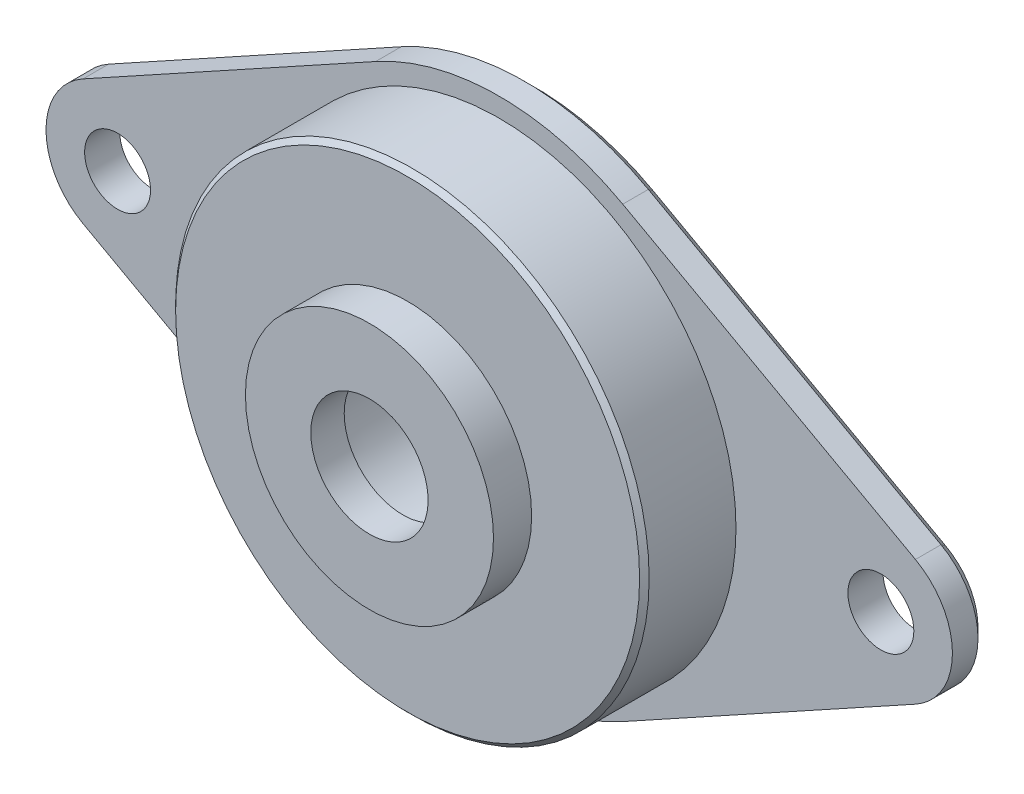
from build123d import *

# Parameters (mm, degrees)
SKETCH2_R           = 6.5
BOSS_EXTRUDE1_DEPTH = 2
BOSS_EXTRUDE2_DEPTH = 1.84
CHAMFER1_SIZE       = 0.25
CHAMFER2_SIZE       = 0.5


with BuildPart() as part:
    # Sketch1 → Revolve1 (revolve)
    with BuildSketch(Plane(origin=(0, 0, 0), x_dir=(1, 0, 0), z_dir=(0, 1, 0))):
        Polygon((0, 0), (12.4079, 0), (12.4079, 4.8), (13.4079, 4.8), (13.4079, 6.64), (0, 6.64), align=None)
    revolve(axis=Axis((0, 0, 0), (0, 0, -1)))

    # Sketch2 → Boss-Extrude1 (add)
    with BuildSketch(Plane.XY):
        Circle(SKETCH2_R)
    extrude(amount=BOSS_EXTRUDE1_DEPTH)

    # Sketch3 → Boss-Extrude2 (add)
    with BuildSketch(Plane(origin=(0, 0, -6.64), x_dir=(-1, 0, 0), z_dir=(0, 0, -1))):
        with BuildLine():
            Line((-21.81085625, -3.283793483), (-6.47460787, -11.741006572))
            ThreePointArc((-6.47460787, -11.741006572), (-13.4079, 0), (-6.474607871, 11.741006572))
            Line((-6.474607871, 11.741006572), (-21.81085625, 3.283793483))
            ThreePointArc((-21.81085625, 3.283793483), (-23.75, 0), (-21.81085625, -3.283793483))
        make_face()
    boss_extrude2 = extrude(amount=-BOSS_EXTRUDE2_DEPTH)

    # Sketch4 → #4 Clearance Hole1 (revolve, cut)
    with BuildSketch(Plane(origin=(20, 0, -6.64), x_dir=(0, 1, 0), z_dir=(1, 0, 0))):
        Polygon((0, 0), (0, 16.037806461), (1.7272, 15), (1.7272, 0), align=None)
    f_4_clearance_hole1 = revolve(axis=Axis((20, 0, -12.99), (0, 0, 1)), mode=Mode.SUBTRACT)

    # Mirror1: Boss-Extrude2, #4 Clearance Hole1 across plane
    add(boss_extrude2.mirror(Plane(origin=(0, 0, 0), x_dir=(0, 0, 1), z_dir=(1, 0, 0))))
    add(f_4_clearance_hole1.mirror(Plane(origin=(0, 0, 0), x_dir=(0, 0, 1), z_dir=(1, 0, 0))), mode=Mode.SUBTRACT)

    # Sketch8 → 1/16 NPT Tapped Hole2 (revolve, cut)
    with BuildSketch(Plane(origin=(0, 0, -6.64), x_dir=(0, 1, 0), z_dir=(1, 0, 0))):
        Polygon((0, 0), (0, 8.64), (3.0734, 8.64), (3.0734, 6.89), (3.781593923, 6.89), (3.968877, 0.635), (4.603877, 0), align=None)
    revolve(axis=Axis((0, 0, -12.99), (0, 0, 1)), mode=Mode.SUBTRACT)

    # Chamfer1
    chamfer1_edges = [part.edges().sort_by_distance(p)[0] for p in [
        (-12.4079, 0, 0),
    ]]
    chamfer(chamfer1_edges, length=CHAMFER1_SIZE)

    # Chamfer2
    chamfer2_edges = [part.edges().sort_by_distance(p)[0] for p in [
        (23.75, 0, -6.64),
        (14.14273206, -7.512400028, -6.64),
        (14.14273206, 7.512400028, -6.64),
        (0, -13.4079, -6.64),
        (-23.75, 0, -6.64),
        (-14.14273206, -7.512400028, -6.64),
        (-14.14273206, 7.512400028, -6.64),
        (0, 13.4079, -6.64),
    ]]
    chamfer(chamfer2_edges, length=CHAMFER2_SIZE)


solid = part.part
